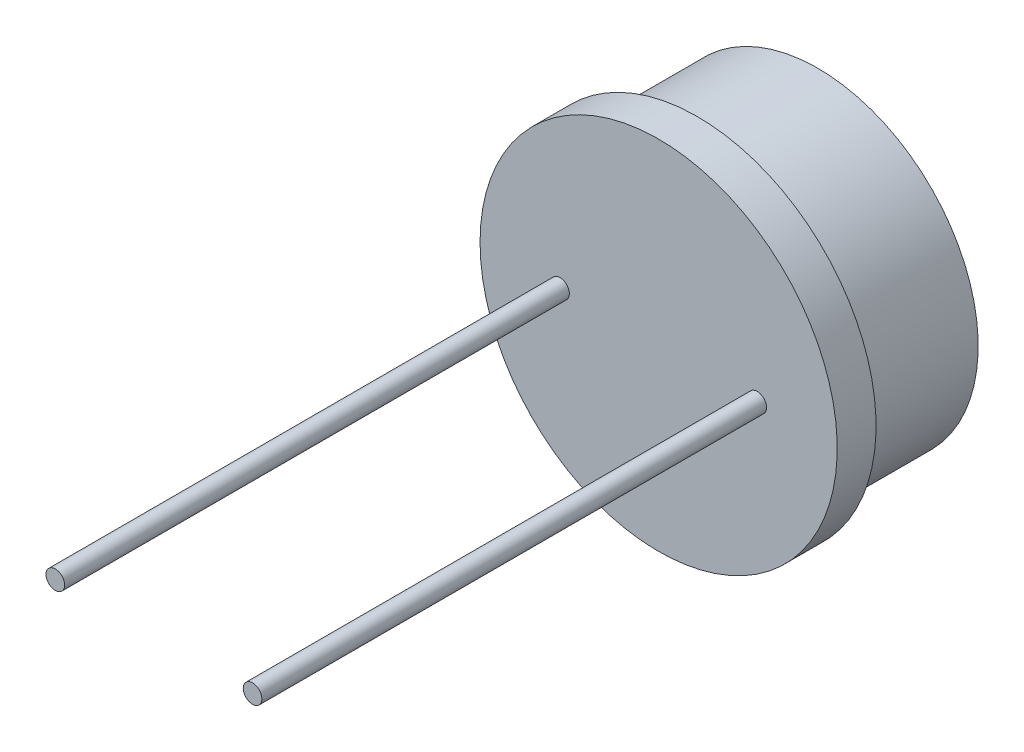
from build123d import *

# Parameters (mm, degrees)
SKETCH2_R           = 0.24
BOSS_EXTRUDE1_DEPTH = 13


with BuildPart() as part:
    # Sketch1 → Revolve1 (revolve)
    with BuildSketch(Plane(origin=(0, 0, 0), x_dir=(1, 0, 0), z_dir=(0, 1, 0))):
        Polygon((0, 0), (4.6, 0), (4.6, 1), (4.13, 1), (4.13, 4.1), (3.63, 4.1), (3.63, 3.9), (0, 3.9), align=None)
    revolve(axis=Axis((0, 0, -3.9), (0, 0, 1)))

    # Sketch2 → Boss-Extrude1 (add)
    with BuildSketch(Plane.XY):
        with Locations((-2.54, 0)):
            Circle(SKETCH2_R)
        with Locations((2.54, 0)):
            Circle(SKETCH2_R)
    extrude(amount=BOSS_EXTRUDE1_DEPTH)


solid = part.part
